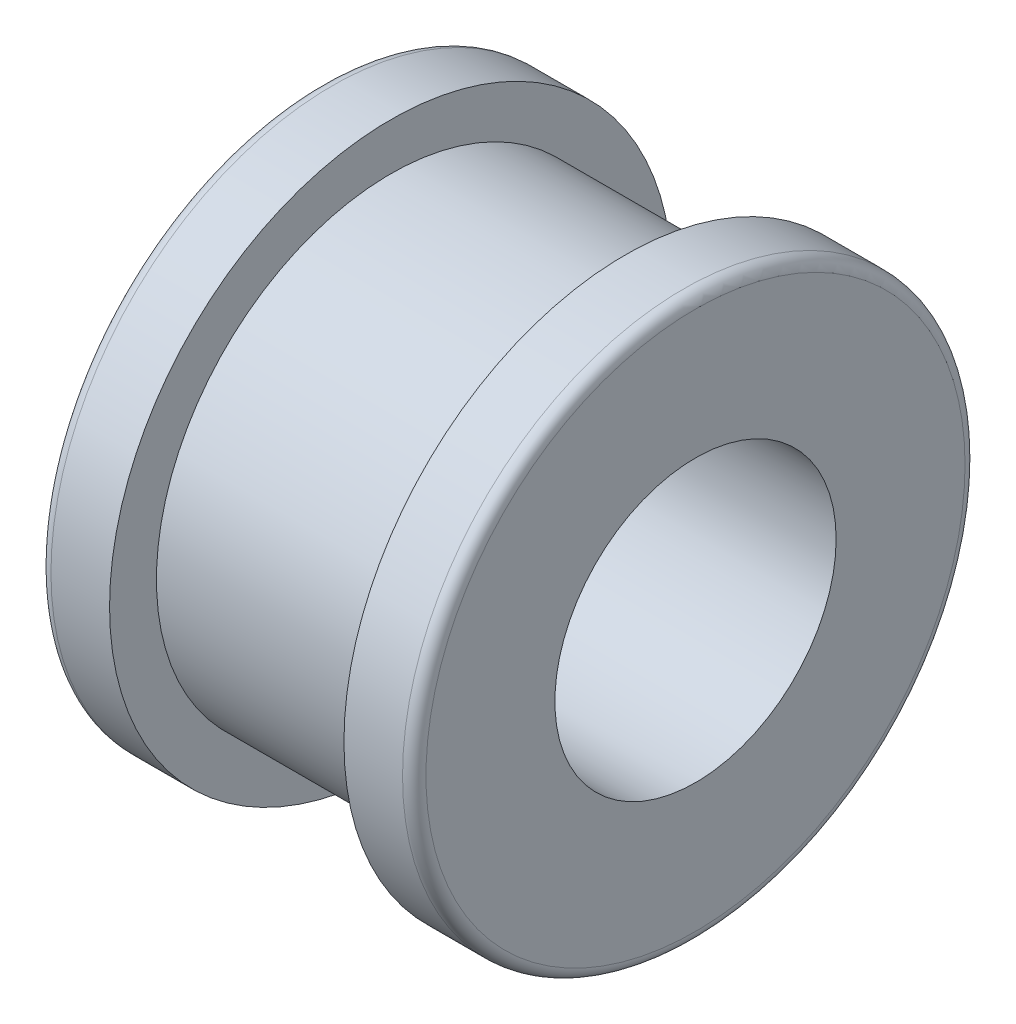
from build123d import *

# Parameters (mm, degrees)
SKETCH_2_R               = 12
EXTRUDE_1_DEPTH          = 8
SKETCH_3_R               = 12
SKETCH_3_R_2             = 10
CUT_EXTRUDE_1_DEPTH      = 5
SKETCH_4_R               = 6
CUT_EXTRUDE_2_DEPTH      = 9
CUT_EXTRUDE_2_DEPTH_BACK = 9
FILLET_1_R               = 0.5
SKETCH_5_R               = 1
CUT_EXTRUDE_3_DEPTH      = 10


with BuildPart() as part:
    # 草图2 → 凸台-拉伸1 (new body, symmetric)
    with BuildSketch(Plane(origin=(0, 0, 0), x_dir=(0, 0, -1), z_dir=(1, 0, 0))):
        Circle(SKETCH_2_R)
    extrude(amount=EXTRUDE_1_DEPTH, both=True)

    # 草图3 → 切除-拉伸1 (cut, symmetric)
    with BuildSketch(Plane(origin=(0, 0, 0), x_dir=(0, 0, -1), z_dir=(1, 0, 0))):
        Circle(SKETCH_3_R)
        Circle(SKETCH_3_R_2, mode=Mode.SUBTRACT)
    extrude(amount=CUT_EXTRUDE_1_DEPTH, both=True, mode=Mode.SUBTRACT)

    # 草图4 → 切除-拉伸2 (cut, two sides)
    with BuildSketch(Plane(origin=(0, 0, 0), x_dir=(0, 0, -1), z_dir=(1, 0, 0))) as cut_extrude_2_sk:
        Circle(SKETCH_4_R)
    extrude(amount=CUT_EXTRUDE_2_DEPTH, mode=Mode.SUBTRACT)
    extrude(cut_extrude_2_sk.sketch, amount=-CUT_EXTRUDE_2_DEPTH_BACK, mode=Mode.SUBTRACT)

    # 圆角1
    fillet_1_edges = [part.edges().sort_by_distance(p)[0] for p in [
        (-8, 0, 12),
        (8, 0, 12),
    ]]
    fillet(fillet_1_edges, radius=FILLET_1_R)

    # 草图5 → 切除-拉伸3 (cut)
    with BuildSketch(Plane(origin=(0, 0, 0), x_dir=(1, 0, 0), z_dir=(0, 1, 0))):
        Circle(SKETCH_5_R)
    extrude(amount=-CUT_EXTRUDE_3_DEPTH, mode=Mode.SUBTRACT)


solid = part.part
